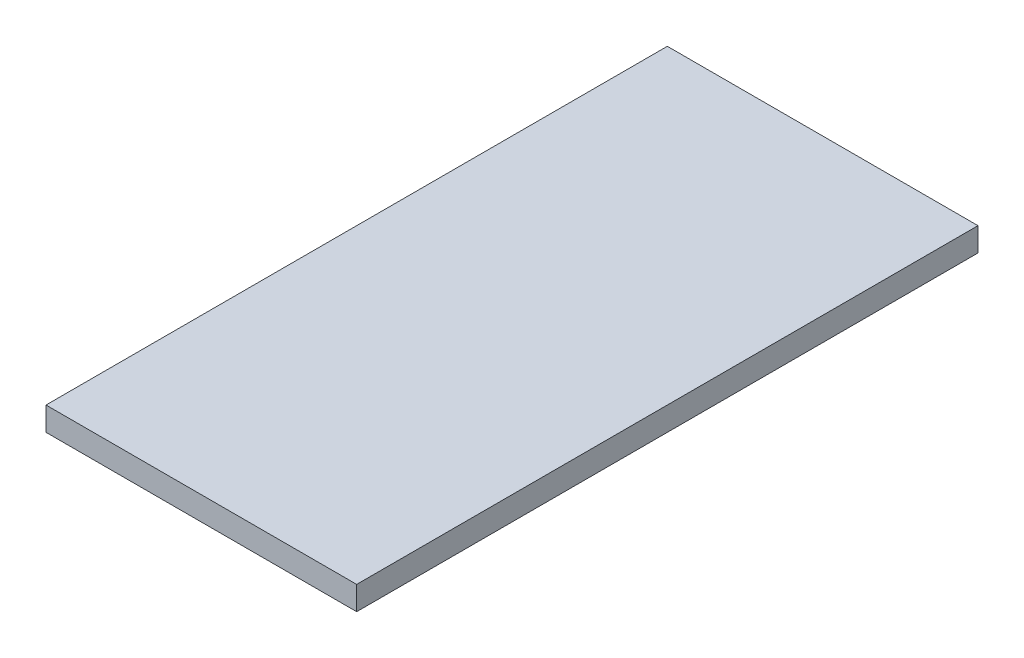
from build123d import *

# Parameters (mm, degrees)
SKETCH1_W           = 12.7
SKETCH1_H           = 25.4
BOSS_EXTRUDE1_DEPTH = 0.96774


with BuildPart() as part:
    # Sketch1 → Boss-Extrude1 (new body)
    with BuildSketch(Plane(origin=(0, 0, 0), x_dir=(1, 0, 0), z_dir=(0, 1, 0))):
        Rectangle(SKETCH1_W, SKETCH1_H)
    extrude(amount=BOSS_EXTRUDE1_DEPTH)


solid = part.part
